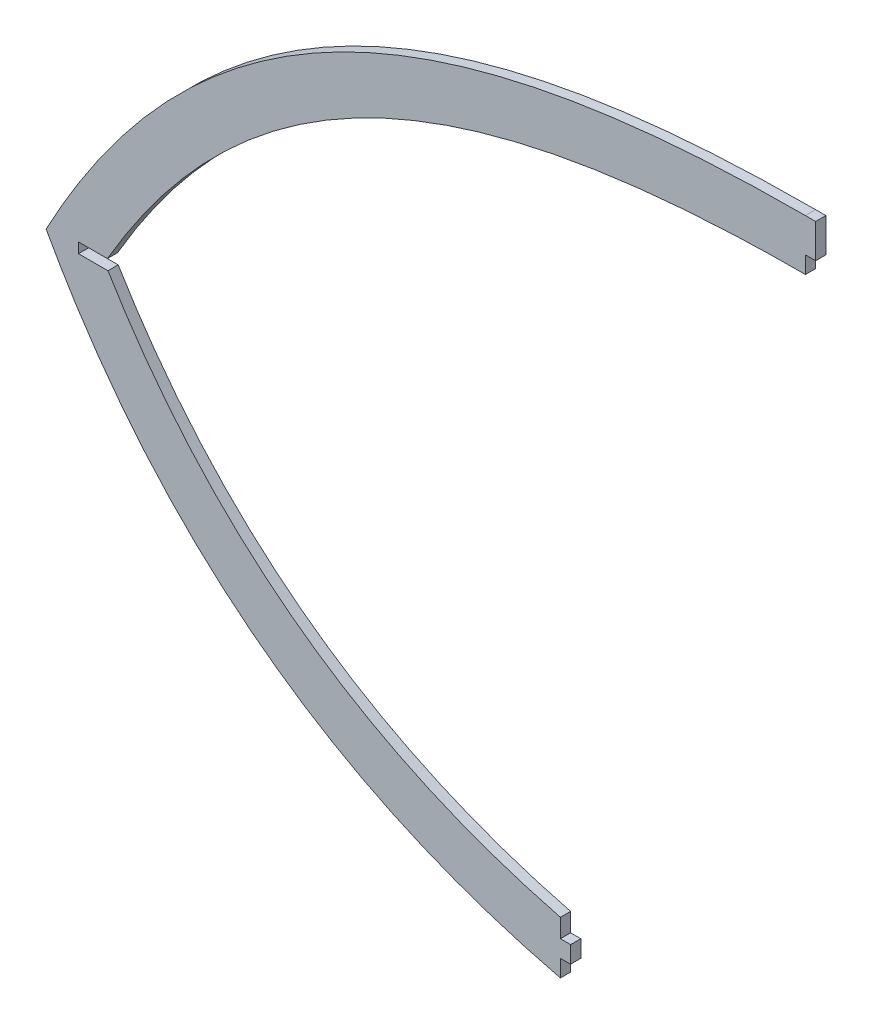
from build123d import *

# Parameters (mm, degrees)
BOSS_EXTRUDE1_DEPTH = 1.5


with BuildPart() as part:
    # Sketch1 → Boss-Extrude1 (new, symmetric)
    with BuildSketch(Plane.XY):
        with BuildLine():
            Line((-83, 150.5), (-80, 150.5))
            Line((-80, 150.5), (-80, 160.5))
            Line((-80, 160.5), (-83, 160.5))
            add(Edge.make_bspline(
                [(-83, 160.5), (-186.674882328, 160.5), (-259.899625943, 132.369993049), (-306.089272366, 45.5)],
                knots=[0, 0, 0, 0, 1, 1, 1, 1], degree=3))
            add(Edge.make_bspline(
                [(-155, -69.5), (-256.223953913, -45.186386925), (-306.089272366, 45.5)],
                knots=[0, 0, 0, 1, 1, 1], degree=2))
            Line((-155, -69.5), (-154.999999917, -64.5))
            Line((-154.999999917, -64.5), (-152, -64.5))
            Line((-152, -64.5), (-152, -59.5))
            Line((-152, -59.5), (-154.999999917, -59.5))
            Line((-154.999999917, -59.5), (-154.999999917, -54.048230847))
            add(Edge.make_bspline(
                [(-154.999999917, -54.048230847), (-155.731391017, -53.861952556), (-158.35300609, -53.18251016), (-164.660079812, -51.441937103), (-173.748401065, -48.593950888), (-184.269254843, -44.741272938), (-197.799811005, -39.023974286), (-213.789585617, -30.792816145), (-231.54938628, -19.175615564), (-247.929147797, -5.797107699), (-260.461993531, 6.849243634), (-269.830689916, 17.887635578), (-276.528905481, 26.631356248), (-281.840565627, 34.314662243), (-285.585788565, 40.16703977), (-287.259111537, 42.898020189), (-287.922750115, 44.000000102)],
                knots=[0.497752743, 0.497752743, 0.497752743, 0.497752743, 0.497805621, 0.497942734, 0.498216959, 0.498491185, 0.49876541, 0.499313861, 0.499862311, 0.500410762, 0.500959213, 0.501233438, 0.501507663, 0.501781889, 0.501919001, 0.502011047, 0.502011047, 0.502011047, 0.502011047], degree=3))
            Line((-287.922750115, 44.000000102), (-296.595237141, 44))
            Line((-296.595237141, 44), (-296.595237141, 47))
            Line((-296.595237141, 47), (-288.095237155, 46.999999977))
            add(Edge.make_bspline(
                [(-288.095237155, 46.999999977), (-287.67425608, 47.723773029), (-286.556391538, 49.623615877), (-284.033138295, 53.780945513), (-280.456261147, 59.345240484), (-276.041179686, 65.705065743), (-269.986302057, 73.779240653), (-262.103210513, 83.128273836), (-252.129600389, 93.224723366), (-241.623487548, 102.265543316), (-226.8699821, 112.996693644), (-206.95054411, 124.077334491), (-184.837162494, 132.347816663), (-165.731643324, 137.402287642), (-150.68126183, 140.438776977), (-134.89929995, 142.748064465), (-121.133672011, 144.089727596), (-109.75100783, 144.828269011), (-101.030097883, 145.218689511), (-93.605076071, 145.411132847), (-87.580198375, 145.487405992), (-84.523017423, 145.5), (-83, 145.5)],
                knots=[0.005881872, 0.005881872, 0.005881872, 0.005881872, 0.01516131, 0.03032262, 0.060645241, 0.090967861, 0.121290481, 0.181935722, 0.242580962, 0.303226203, 0.363871444, 0.485161925, 0.606452406, 0.667097647, 0.727742887, 0.788388128, 0.849033368, 0.879355989, 0.909678609, 0.940001229, 0.955162539, 0.97032385, 0.97032385, 0.97032385, 0.97032385], degree=3))
            Line((-83, 145.5), (-83, 150.5))
        make_face()
    extrude(amount=BOSS_EXTRUDE1_DEPTH, both=True)


solid = part.part
